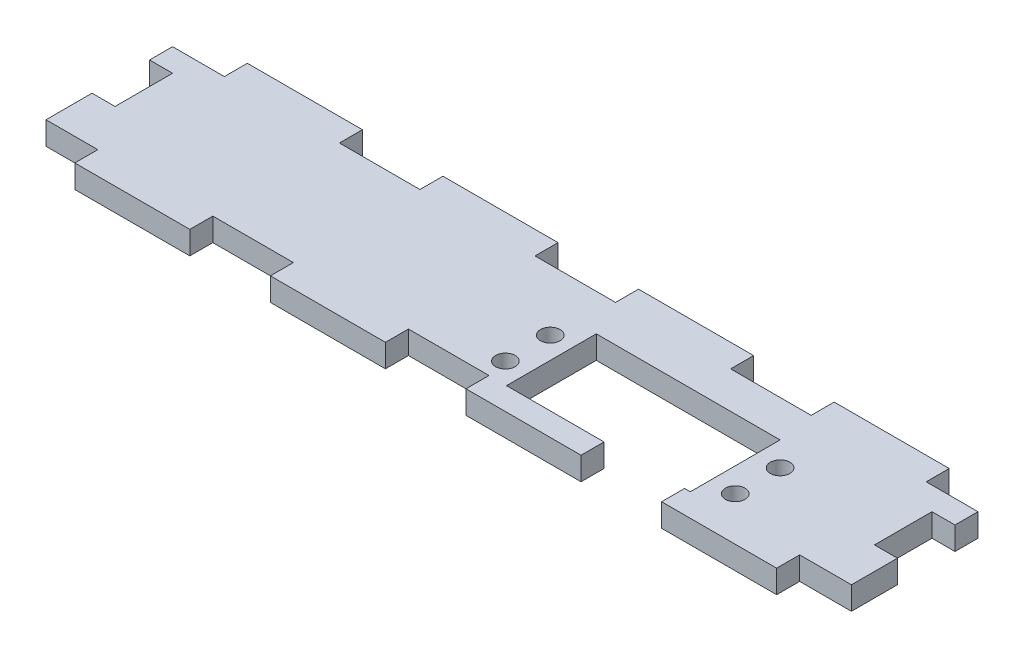
from build123d import *

# Parameters (mm, degrees)
SKETCH1_W           = 177.8
SKETCH1_H           = 38.1
BOSS_EXTRUDE1_DEPTH = 5.08
SKETCH2_W           = 11.43
SKETCH2_H           = 5.08
CUT_EXTRUDE1_DEPTH  = 5.08
SKETCH3_W           = 11.43
SKETCH3_H           = 5.08
CUT_EXTRUDE2_DEPTH  = 5.08
SKETCH4_W           = 17.78
SKETCH4_H           = 5.08
CUT_EXTRUDE3_DEPTH  = 5.08
LPATTERN1_COUNT     = 3
LPATTERN1_PITCH     = 43.18
SKETCH5_W           = 40.5765
SKETCH5_H           = 19.812
CUT_EXTRUDE4_DEPTH  = 5.08
SKETCH6_W           = 5.08
SKETCH6_H           = 12.7
CUT_EXTRUDE5_DEPTH  = 5.08
SKETCH7_W           = 11.43
SKETCH7_H           = 5.08
SKETCH7_W_2         = 17.78
CUT_EXTRUDE6_DEPTH  = 5.08
SKETCH8_W           = 17.78
SKETCH8_H           = 5.08
CUT_EXTRUDE7_DEPTH  = 5.08
LPATTERN2_COUNT     = 2
LPATTERN2_PITCH     = 43.18
SKETCH9_W           = 5.08
SKETCH9_H           = 12.7
CUT_EXTRUDE8_DEPTH  = 5.08
SKETCH10_R          = 2.159
CUT_EXTRUDE9_DEPTH  = 5.08


with BuildPart() as part:
    # Sketch1 → Boss-Extrude1 (new body)
    with BuildSketch(Plane(origin=(0, 0, 0), x_dir=(1, 0, 0), z_dir=(0, 1, 0))):
        with Locations((-88.9, -19.05)):
            Rectangle(SKETCH1_W, SKETCH1_H)
    extrude(amount=BOSS_EXTRUDE1_DEPTH)

    # Sketch2 → Cut-Extrude1 (cut)
    with BuildSketch(Plane(origin=(0, 5.08, 0), x_dir=(1, 0, 0), z_dir=(0, 1, 0))):
        with Locations((-172.085, -35.56)):
            Rectangle(SKETCH2_W, SKETCH2_H)
    extrude(amount=-CUT_EXTRUDE1_DEPTH, mode=Mode.SUBTRACT)

    # Sketch3 → Cut-Extrude2 (cut)
    with BuildSketch(Plane(origin=(0, 5.08, 0), x_dir=(1, 0, 0), z_dir=(0, 1, 0))):
        with Locations((-5.715, -35.56)):
            Rectangle(SKETCH3_W, SKETCH3_H)
    extrude(amount=-CUT_EXTRUDE2_DEPTH, mode=Mode.SUBTRACT)

    # Sketch4 → Cut-Extrude3 (cut)
    with BuildSketch(Plane(origin=(0, 5.08, 0), x_dir=(1, 0, 0), z_dir=(0, 1, 0))):
        with Locations((-132.08, -35.56)):
            Rectangle(SKETCH4_W, SKETCH4_H)
    cut_extrude3 = extrude(amount=-CUT_EXTRUDE3_DEPTH, mode=Mode.SUBTRACT)

    # LPattern1: Cut-Extrude3 ×3
    with Locations(*[(i * LPATTERN1_PITCH, 0, 0) for i in range(1, LPATTERN1_COUNT)]):
        add(cut_extrude3, mode=Mode.SUBTRACT)

    # Sketch5 → Cut-Extrude4 (cut)
    with BuildSketch(Plane(origin=(0, 5.08, 0), x_dir=(1, 0, 0), z_dir=(0, 1, 0))):
        with Locations((-55.84825, -23.114)):
            Rectangle(SKETCH5_W, SKETCH5_H)
    extrude(amount=-CUT_EXTRUDE4_DEPTH, mode=Mode.SUBTRACT)

    # Sketch6 → Cut-Extrude5 (cut)
    with BuildSketch(Plane(origin=(0, 0, 0), x_dir=(-1, 0, 0), z_dir=(0, -1, 0))):
        with Locations((2.54, -16.51)):
            Rectangle(SKETCH6_W, SKETCH6_H)
    extrude(amount=-CUT_EXTRUDE5_DEPTH, mode=Mode.SUBTRACT)

    # Sketch7 → Cut-Extrude6 (cut)
    with BuildSketch(Plane(origin=(0, 5.08, 0), x_dir=(1, 0, 0), z_dir=(0, 1, 0))):
        with Locations((-172.085, -2.54)):
            Rectangle(SKETCH7_W, SKETCH7_H)
        with Locations((-132.08, -2.54)):
            Rectangle(SKETCH7_W_2, SKETCH7_H)
        with Locations((-5.715, -2.54)):
            Rectangle(SKETCH7_W, SKETCH7_H)
    extrude(amount=-CUT_EXTRUDE6_DEPTH, mode=Mode.SUBTRACT)

    # Sketch8 → Cut-Extrude7 (cut)
    with BuildSketch(Plane(origin=(0, 5.08, 0), x_dir=(1, 0, 0), z_dir=(0, 1, 0))):
        with Locations((-88.9, -2.54)):
            Rectangle(SKETCH8_W, SKETCH8_H)
    cut_extrude7 = extrude(amount=-CUT_EXTRUDE7_DEPTH, mode=Mode.SUBTRACT)

    # LPattern2: Cut-Extrude7 ×2
    with Locations(*[(i * LPATTERN2_PITCH, 0, 0) for i in range(1, LPATTERN2_COUNT)]):
        add(cut_extrude7, mode=Mode.SUBTRACT)

    # Sketch9 → Cut-Extrude8 (cut)
    with BuildSketch(Plane(origin=(0, 5.08, 0), x_dir=(1, 0, 0), z_dir=(0, 1, 0))):
        with Locations((-175.26, -16.51)):
            Rectangle(SKETCH9_W, SKETCH9_H)
    extrude(amount=-CUT_EXTRUDE8_DEPTH, mode=Mode.SUBTRACT)

    # Sketch10 → Cut-Extrude9 (cut)
    with BuildSketch(Plane.XZ):
        with Locations((-80.9625, 18.542)):
            Circle(SKETCH10_R)
        with Locations((-80.9625, 28.448)):
            Circle(SKETCH10_R)
        with Locations((-30.226, 28.448)):
            Circle(SKETCH10_R)
        with Locations((-30.226, 18.542)):
            Circle(SKETCH10_R)
    extrude(amount=-CUT_EXTRUDE9_DEPTH, mode=Mode.SUBTRACT)


solid = part.part
